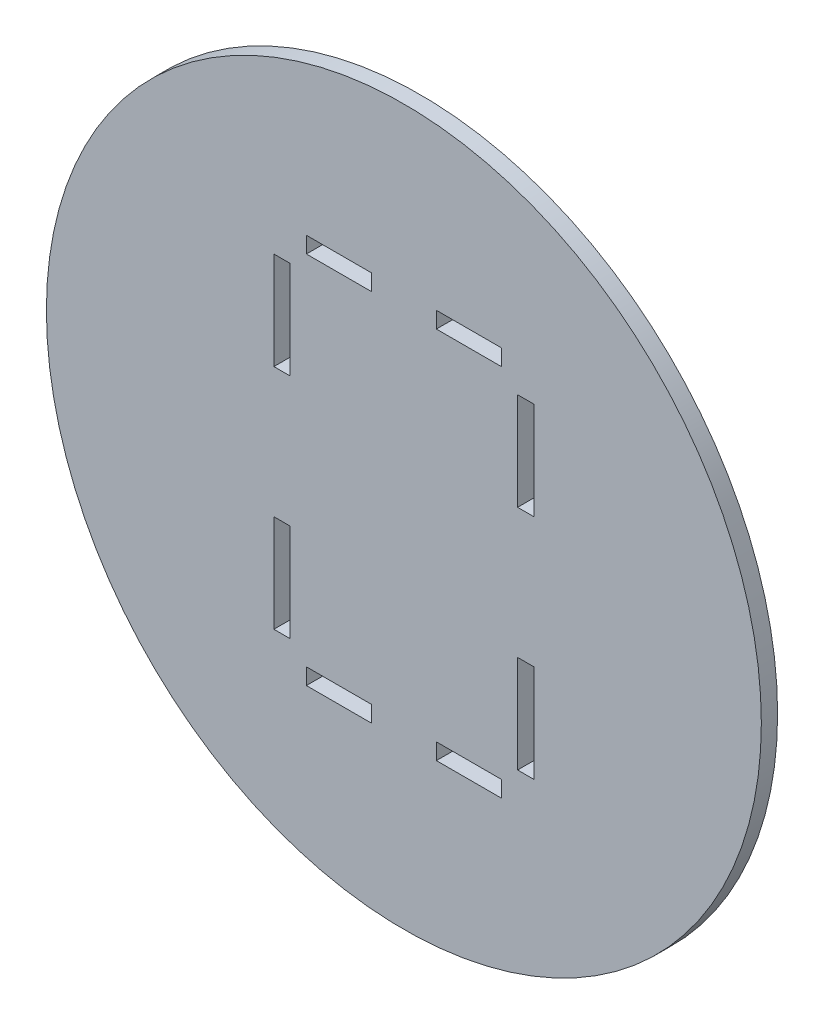
from build123d import *

# Parameters (mm, degrees)
SKETCH1_R           = 110
SKETCH1_W           = 20
SKETCH1_H           = 5
SKETCH1_W_2         = 5
SKETCH1_H_2         = 30
BOSS_EXTRUDE1_DEPTH = 5


with BuildPart() as part:
    # Sketch1 → Boss-Extrude1 (new body)
    with BuildSketch(Plane.XY):
        Circle(SKETCH1_R)
        with Locations((-20, 57.5)):
            Rectangle(SKETCH1_W, SKETCH1_H, mode=Mode.SUBTRACT)
        with Locations((20, 57.5)):
            Rectangle(SKETCH1_W, SKETCH1_H, mode=Mode.SUBTRACT)
        with Locations((37.5, 35)):
            Rectangle(SKETCH1_W_2, SKETCH1_H_2, mode=Mode.SUBTRACT)
        with Locations((37.5, -35)):
            Rectangle(SKETCH1_W_2, SKETCH1_H_2, mode=Mode.SUBTRACT)
        with Locations((20, -57.5)):
            Rectangle(SKETCH1_W, SKETCH1_H, mode=Mode.SUBTRACT)
        with Locations((-20, -57.5)):
            Rectangle(SKETCH1_W, SKETCH1_H, mode=Mode.SUBTRACT)
        with Locations((-37.5, -35)):
            Rectangle(SKETCH1_W_2, SKETCH1_H_2, mode=Mode.SUBTRACT)
        with Locations((-37.5, 35)):
            Rectangle(SKETCH1_W_2, SKETCH1_H_2, mode=Mode.SUBTRACT)
    extrude(amount=BOSS_EXTRUDE1_DEPTH)


solid = part.part
